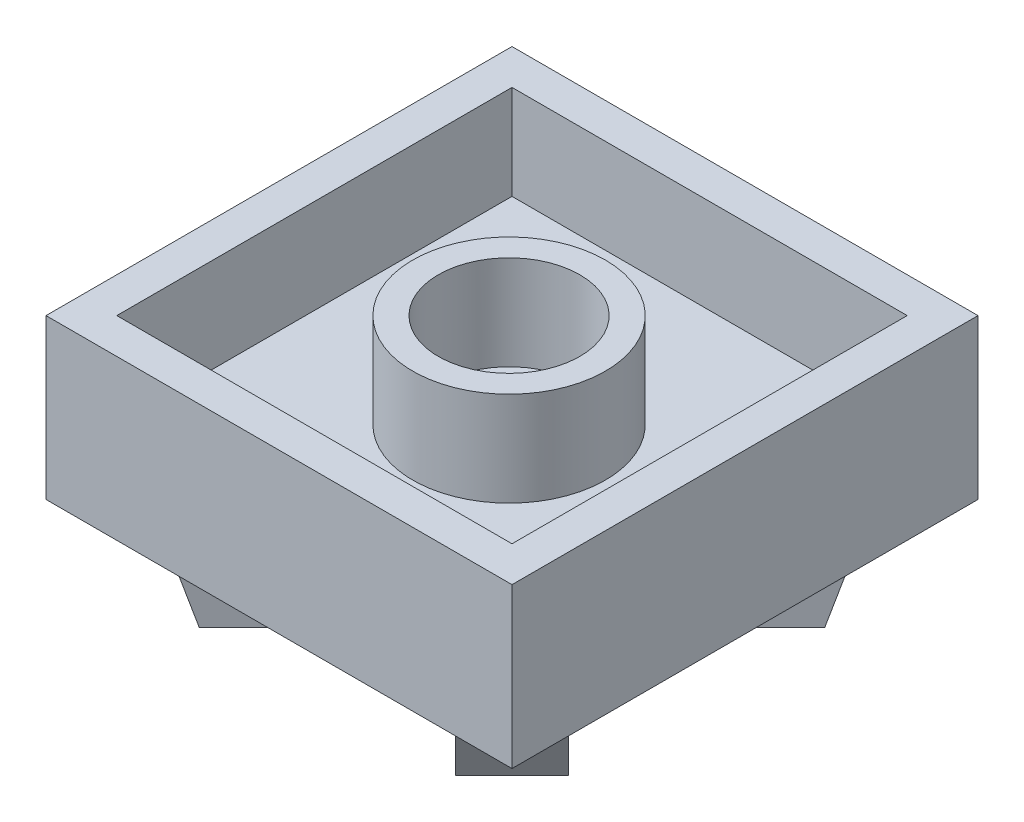
from build123d import *

# Parameters (mm, degrees)
SKETCH2_W            = 15.8
SKETCH2_H            = 15.8
BOSS_EXTRUDE2_DEPTH  = 5.4
SKETCH4_W            = 13.4
SKETCH4_H            = 13.4
CUT_EXTRUDE1_DEPTH   = 3.2
SKETCH7_R            = 3.265
SKETCH7_R_2          = 2.4
BOSS_EXTRUDE5_DEPTH  = 3.2
SKETCH8_R            = 5.15
CUT_EXTRUDE2_DEPTH   = 0.3
BOSS_EXTRUDE8_DEPTH  = 2.8
BOSS_EXTRUDE11_DEPTH = 2.7
CIRPATTERN1_COUNT    = 4


with BuildPart() as part:
    # Sketch2 → Boss-Extrude2 (new body)
    with BuildSketch(Plane(origin=(0, 0, 0), x_dir=(1, 0, 0), z_dir=(0, 1, 0))):
        with Locations((7.9, 7.9)):
            Rectangle(SKETCH2_W, SKETCH2_H)
    extrude(amount=-BOSS_EXTRUDE2_DEPTH)

    # Sketch4 → Cut-Extrude1 (cut)
    with BuildSketch(Plane(origin=(0, 0, 0), x_dir=(1, 0, 0), z_dir=(0, 1, 0))):
        with Locations((7.9, 7.9)):
            Rectangle(SKETCH4_W, SKETCH4_H)
    extrude(amount=-CUT_EXTRUDE1_DEPTH, mode=Mode.SUBTRACT)

    # Sketch7 → Boss-Extrude5 (add)
    with BuildSketch(Plane(origin=(0, -3.2, 0), x_dir=(1, 0, 0), z_dir=(0, 1, 0))):
        with Locations((7.85, 7.85)):
            Circle(SKETCH7_R)
        with Locations((7.85, 7.85)):
            Circle(SKETCH7_R_2, mode=Mode.SUBTRACT)
    extrude(amount=BOSS_EXTRUDE5_DEPTH)

    # Sketch8 → Cut-Extrude2 (cut)
    with BuildSketch(Plane(origin=(0, -5.4, 0), x_dir=(-1, 0, 0), z_dir=(0, -1, 0))):
        with Locations((-7.9, 7.9)):
            Circle(SKETCH8_R)
    extrude(amount=-CUT_EXTRUDE2_DEPTH, mode=Mode.SUBTRACT)

    # Sketch11 → Boss-Extrude8 (add)
    with BuildSketch(Plane.XZ.offset(5.4)):
        Polygon((11.683021279, -2.207790411), (12.637615434, -3.162384566), (13.203300859, -2.596699141), (12.248706704, -1.642104986), align=None)
        with BuildLine():
            ThreePointArc((11.585853022, -2.304958669), (12.133497372, -2.706975833), (12.637615434, -3.162384566))
            Line((12.637615434, -3.162384566), (11.683021279, -2.207790411))
            Line((11.683021279, -2.207790411), (11.585853022, -2.304958669))
        make_face()
        with BuildLine():
            ThreePointArc((10.459662524, -3.431149167), (11.028098464, -3.808851017), (11.541599923, -4.258400077))
            Line((11.541599923, -4.258400077), (12.637615434, -3.162384566))
            ThreePointArc((12.637615434, -3.162384566), (12.133497372, -2.706975833), (11.585853022, -2.304958669))
            Line((11.585853022, -2.304958669), (10.459662524, -3.431149167))
        make_face()
        with BuildLine():
            Line((12.637615434, -3.162384566), (11.541599923, -4.258400077))
            ThreePointArc((11.541599923, -4.258400077), (11.991148983, -4.771901536), (12.368850833, -5.340337476))
            Line((12.368850833, -5.340337476), (13.495041331, -4.214146978))
            ThreePointArc((13.495041331, -4.214146978), (13.093024167, -3.666502628), (12.637615434, -3.162384566))
        make_face()
        with BuildLine():
            Line((13.592209589, -4.116978721), (12.637615434, -3.162384566))
            ThreePointArc((12.637615434, -3.162384566), (13.093024167, -3.666502628), (13.495041331, -4.214146978))
            Line((13.495041331, -4.214146978), (13.592209589, -4.116978721))
        make_face()
        Polygon((13.203300859, -2.596699141), (12.637615434, -3.162384566), (13.592209589, -4.116978721), (14.157895014, -3.551293296), align=None)
    boss_extrude8 = extrude(amount=BOSS_EXTRUDE8_DEPTH)

    # Sketch29 → Boss-Extrude11 (add)
    with BuildSketch(Plane(origin=(6.945405845, 0, -6.945405845), x_dir=(0.707106781, 0, 0.707106781), z_dir=(-0.707106781, 0, 0.707106781))):
        Polygon((7.5, -8.2), (7.5, -5.4), (8.4, -5.4), align=None)
    boss_extrude11 = extrude(amount=-BOSS_EXTRUDE11_DEPTH)

    # CirPattern1: Boss-Extrude8, Boss-Extrude11 ×4 about axis
    cirpattern1_axis = Axis((7.9, 0, -7.9), (0, 1, 0))
    for i in range(1, CIRPATTERN1_COUNT):
        add(boss_extrude8.rotate(cirpattern1_axis, i * 360 / CIRPATTERN1_COUNT))
        add(boss_extrude11.rotate(cirpattern1_axis, i * 360 / CIRPATTERN1_COUNT))


solid = part.part
